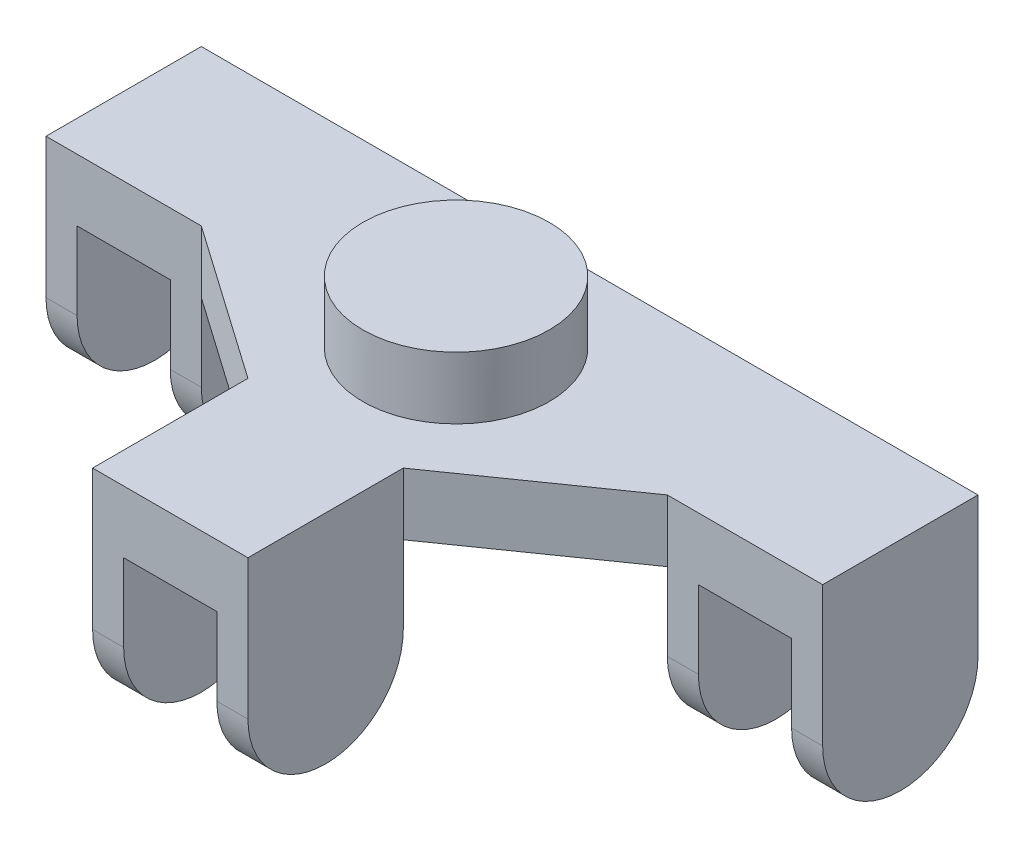
from build123d import *

# Parameters (mm, degrees)
EXTRUDE_1_DEPTH     = 4
SKETCH_1_W          = 10
SKETCH_1_H          = 10
EXTRUDE_2_DEPTH     = 10
SKETCH_3_W          = 6
SKETCH_3_H          = 12.745836759
SKETCH_3_H_2        = 13.387334875
CUT_EXTRUDE_1_DEPTH = 28
CUT_EXTRUDE_2_DEPTH = 51
SKETCH_5_R          = 6
EXTRUDE_3_DEPTH     = 4


with BuildPart() as part:
    # 草图2 → 凸台-拉伸1 (new body)
    with BuildSketch(Plane(origin=(0, 0, 0), x_dir=(1, 0, 0), z_dir=(0, 1, 0))):
        Polygon((-5, -22), (5, -22), (5, -12), (15, -5), (25, -5), (25, 5), (-25, 5), (-25, -5), (-15, -5), (-5, -12), align=None)
    extrude(amount=EXTRUDE_1_DEPTH)

    # 草图1 → 凸台-拉伸2 (add)
    with BuildSketch(Plane(origin=(0, 0, 0), x_dir=(1, 0, 0), z_dir=(0, 1, 0))):
        with Locations((-20, 0)):
            Rectangle(SKETCH_1_W, SKETCH_1_H)
        with Locations((20, 0)):
            Rectangle(SKETCH_1_W, SKETCH_1_H)
        with Locations((0, -17)):
            Rectangle(SKETCH_1_W, SKETCH_1_H)
    extrude(amount=-EXTRUDE_2_DEPTH)

    # 草图3 → 切除-拉伸1 (cut, through all)
    with BuildSketch(Plane(origin=(0, 0, -5), x_dir=(-1, 0, 0), z_dir=(0, 0, -1))):
        with Locations((-20, -6.37291838)):
            Rectangle(SKETCH_3_W, SKETCH_3_H)
        with Locations((0, -6.37291838)):
            Rectangle(SKETCH_3_W, SKETCH_3_H)
        with Locations((20, -6.693667438)):
            Rectangle(SKETCH_3_W, SKETCH_3_H_2)
    extrude(amount=-CUT_EXTRUDE_1_DEPTH, mode=Mode.SUBTRACT)

    # 草图4 → 切除-拉伸2 (cut, through all)
    with BuildSketch(Plane(origin=(25, 0, 0), x_dir=(0, 0, -1), z_dir=(1, 0, 0))):
        with BuildLine():
            Line((-22, -5), (-22, -12.80603889))
            Line((-22, -12.80603889), (-12, -12.80603889))
            Line((-12, -12.80603889), (-12, -5))
            ThreePointArc((-12, -5), (-17, -10), (-22, -5))
        make_face()
        with BuildLine():
            Line((-5, -5), (-5, -13.738678459))
            Line((-5, -13.738678459), (5, -13.738678459))
            Line((5, -13.738678459), (5, -5))
            ThreePointArc((5, -5), (0, -10), (-5, -5))
        make_face()
    extrude(amount=-CUT_EXTRUDE_2_DEPTH, mode=Mode.SUBTRACT)

    # 草图5 → 凸台-拉伸3 (add)
    with BuildSketch(Plane(origin=(0, 4, 0), x_dir=(1, 0, 0), z_dir=(0, 1, 0))):
        with Locations((0, -3.6)):
            Circle(SKETCH_5_R)
    extrude(amount=EXTRUDE_3_DEPTH)


solid = part.part
